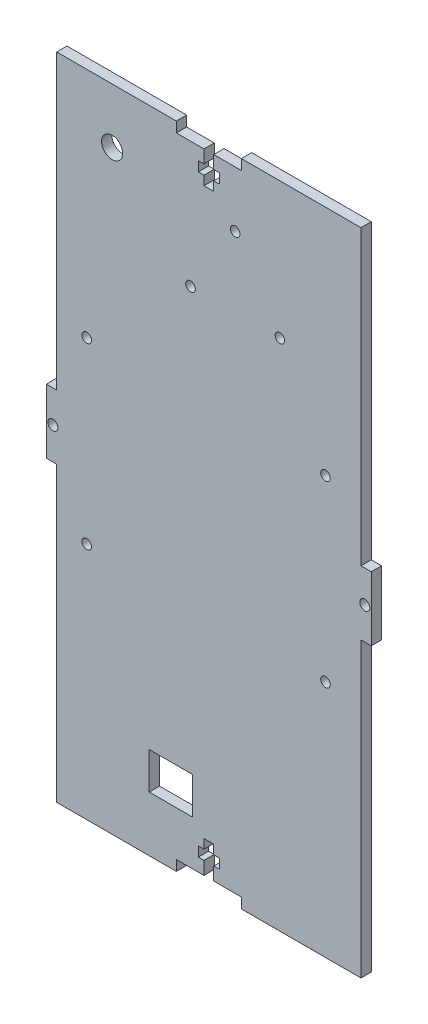
from build123d import *

# Parameters (mm, degrees)
SKETCH1_W           = 100
SKETCH1_H           = 200
BOSS_EXTRUDE2_DEPTH = 3.18
SKETCH2_R           = 1.55
SKETCH2_W           = 3.18
SKETCH2_H           = 90.125
CUT_EXTRUDE1_DEPTH  = 4.18
SKETCH5_R           = 1.47
CUT_EXTRUDE4_DEPTH  = 4.18
SKETCH6_R           = 1.47
CUT_EXTRUDE5_DEPTH  = 4.18
SKETCH4_W           = 13.35
SKETCH4_H           = 11.35
CUT_EXTRUDE7_DEPTH  = 4.18
SKETCH7_R           = 3.25
CUT_EXTRUDE8_DEPTH  = 4.18


with BuildPart() as part:
    # Sketch1 → Boss-Extrude2 (new body)
    with BuildSketch(Plane.XY):
        Rectangle(SKETCH1_W, SKETCH1_H)
    extrude(amount=BOSS_EXTRUDE2_DEPTH)

    # Sketch2 → Cut-Extrude1 (cut, through all)
    with BuildSketch(Plane.XY.offset(3.18)):
        with Locations((-48, 0)):
            Circle(SKETCH2_R)
        Polygon((-10, 100), (-10, 96.82), (-1.5, 96.82), (-1.5, 92.82), (-3.25, 92.82), (-3.25, 89.82), (-1.5, 89.82), (-1.5, 87), (1.5, 87), (1.5, 89.82), (3.25, 89.82), (3.25, 92.82), (1.5, 92.82), (1.5, 96.82), (10, 96.82), (10, 100), align=None)
        with Locations((-48.41, 54.9375)):
            Rectangle(SKETCH2_W, SKETCH2_H)
        with Locations((-48.41, -54.9375)):
            Rectangle(SKETCH2_W, SKETCH2_H)
    cut_extrude1 = extrude(amount=-CUT_EXTRUDE1_DEPTH, mode=Mode.SUBTRACT)

    # Mirror1: Cut-Extrude1 across plane
    add(cut_extrude1.mirror(Plane.ZX), mode=Mode.SUBTRACT)

    # Mirror3: Cut-Extrude1 across plane
    add(cut_extrude1.mirror(Plane(origin=(0, 0, 0), x_dir=(0, 0, 1), z_dir=(1, 0, 0))), mode=Mode.SUBTRACT)

    # Sketch5 → Cut-Extrude4 (cut, through all)
    with BuildSketch(Plane.XY.offset(3.18)):
        with Locations((-37.58090562, 28.464149283)):
            Circle(SKETCH5_R)
        with Locations((35.904481485, 28.464149283)):
            Circle(SKETCH5_R)
        with Locations((-37.58090562, -26.535850717)):
            Circle(SKETCH5_R)
        with Locations((35.904481485, -26.535850717)):
            Circle(SKETCH5_R)
    extrude(amount=-CUT_EXTRUDE4_DEPTH, mode=Mode.SUBTRACT)

    # Sketch6 → Cut-Extrude5 (cut, through all)
    with BuildSketch(Plane.XY.offset(3.18)):
        with Locations((-5.638260743, 58.12)):
            Circle(SKETCH6_R)
        with Locations((8.111739257, 79.62)):
            Circle(SKETCH6_R)
        with Locations((21.861739257, 58.12)):
            Circle(SKETCH6_R)
    extrude(amount=-CUT_EXTRUDE5_DEPTH, mode=Mode.SUBTRACT)

    # Sketch4 → Cut-Extrude7 (cut, through all)
    with BuildSketch(Plane.XY.offset(3.18)):
        with Locations((-11.677157219, -77.351093612)):
            Rectangle(SKETCH4_W, SKETCH4_H)
    extrude(amount=-CUT_EXTRUDE7_DEPTH, mode=Mode.SUBTRACT)

    # Sketch7 → Cut-Extrude8 (cut, through all)
    with BuildSketch(Plane.XY.offset(3.18)):
        with Locations((-29.760307604, 83.086151576)):
            Circle(SKETCH7_R)
    extrude(amount=-CUT_EXTRUDE8_DEPTH, mode=Mode.SUBTRACT)


solid = part.part
